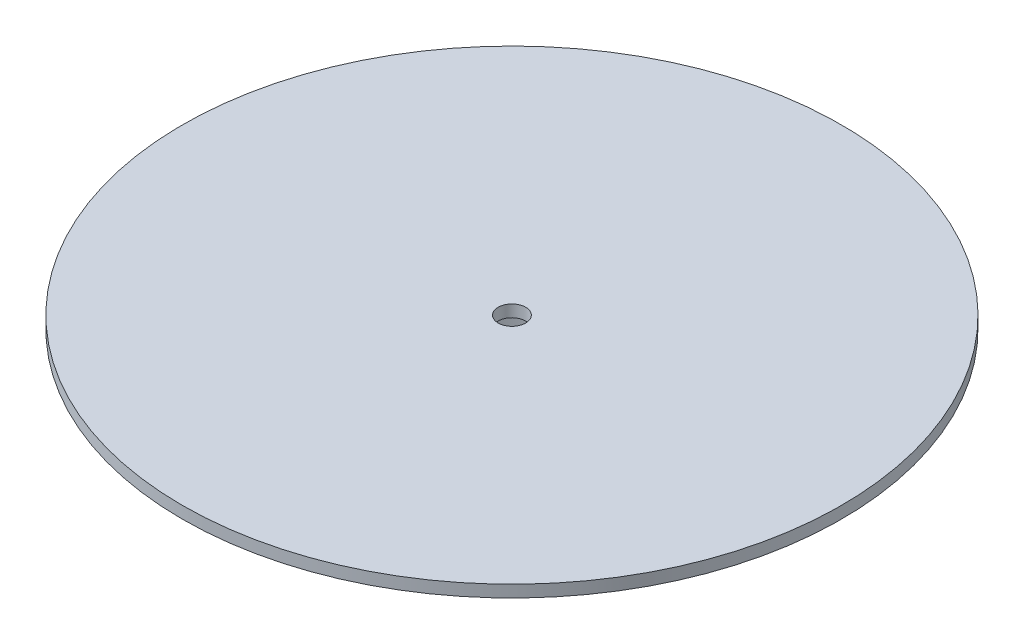
from build123d import *

# Parameters (mm, degrees)
SKETCH1_R           = 76.2
BOSS_EXTRUDE1_DEPTH = 2.76606
SKETCH4_R           = 23.73503
SKETCH4_R_2         = 22.352
BOSS_EXTRUDE3_DEPTH = 35.56
SKETCH5_R           = 3.175
CUT_EXTRUDE1_DEPTH  = 3.76606


with BuildPart() as part:
    # Sketch1 → Boss-Extrude1 (new body)
    with BuildSketch(Plane(origin=(0, 0, 0), x_dir=(1, 0, 0), z_dir=(0, 1, 0))):
        Circle(SKETCH1_R)
    extrude(amount=BOSS_EXTRUDE1_DEPTH)

    # Sketch4 → Boss-Extrude3 (add)
    with BuildSketch(Plane.XZ):
        Circle(SKETCH4_R)
        Circle(SKETCH4_R_2, mode=Mode.SUBTRACT)
    extrude(amount=BOSS_EXTRUDE3_DEPTH)

    # Sketch5 → Cut-Extrude1 (cut, through all)
    with BuildSketch(Plane.XZ):
        Circle(SKETCH5_R)
    extrude(amount=-CUT_EXTRUDE1_DEPTH, mode=Mode.SUBTRACT)


solid = part.part
